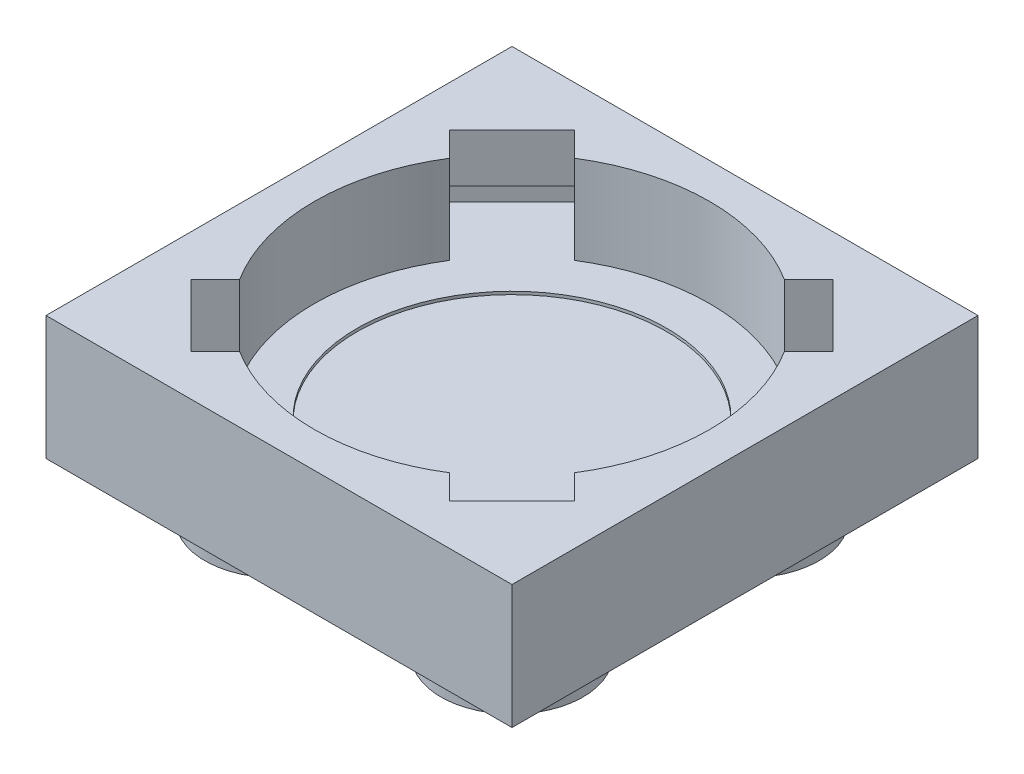
from build123d import *

# Parameters (mm, degrees)
SKETCH2_W            = 15.8
SKETCH2_H            = 15.8
BOSS_EXTRUDE2_DEPTH  = 4.2
SKETCH4_W            = 13.4
SKETCH4_H            = 13.4
CUT_EXTRUDE1_DEPTH   = 3
SKETCH6_R            = 2.41
BOSS_EXTRUDE4_DEPTH  = 1.8
LPATTERN1_COUNT      = 2
LPATTERN1_PITCH      = 8
LPATTERN1_COUNT_DIR2 = 2
LPATTERN1_PITCH_DIR2 = 8
SKETCH8_R            = 5.25
CUT_EXTRUDE2_DEPTH   = 0.1
BOSS_EXTRUDE9_DEPTH  = 3
CUT_EXTRUDE3_DEPTH   = 3
SKETCH20_W           = 3
SKETCH20_H           = 1.35
CUT_EXTRUDE4_DEPTH   = 1.25
CIRPATTERN3_COUNT    = 4


with BuildPart() as part:
    # Sketch2 → Boss-Extrude2 (new body)
    with BuildSketch(Plane(origin=(0, 0, 0), x_dir=(1, 0, 0), z_dir=(0, 1, 0))):
        with Locations((7.9, 7.9)):
            Rectangle(SKETCH2_W, SKETCH2_H)
    extrude(amount=-BOSS_EXTRUDE2_DEPTH)

    # Sketch4 → Cut-Extrude1 (cut)
    with BuildSketch(Plane(origin=(0, 0, 0), x_dir=(1, 0, 0), z_dir=(0, 1, 0))):
        with Locations((7.9, 7.9)):
            Rectangle(SKETCH4_W, SKETCH4_H)
    extrude(amount=-CUT_EXTRUDE1_DEPTH, mode=Mode.SUBTRACT)

    # Sketch6 → Boss-Extrude4 (add)
    with BuildSketch(Plane(origin=(0, -4.2, 0), x_dir=(-1, 0, 0), z_dir=(0, -1, 0))):
        with Locations((-11.9, 11.9)):
            Circle(SKETCH6_R)
    boss_extrude4 = extrude(amount=BOSS_EXTRUDE4_DEPTH)

    # LPattern1: Boss-Extrude4 2 × 2
    with Locations(*[(-j * LPATTERN1_PITCH_DIR2, 0, i * LPATTERN1_PITCH) for i in range(LPATTERN1_COUNT) for j in range(LPATTERN1_COUNT_DIR2) if (i, j) != (0, 0)]):
        add(boss_extrude4)

    # Sketch8 → Cut-Extrude2 (cut)
    with BuildSketch(Plane(origin=(0, -3, 0), x_dir=(1, 0, 0), z_dir=(0, 1, 0))):
        with Locations((7.9, 7.9)):
            Circle(SKETCH8_R)
    extrude(amount=-CUT_EXTRUDE2_DEPTH, mode=Mode.SUBTRACT)

    # Sketch11 → Boss-Extrude9 (add)
    with BuildSketch(Plane(origin=(0, -3, 0), x_dir=(1, 0, 0), z_dir=(0, 1, 0))):
        with BuildLine():
            Line((7.899999971, 14.6), (1.2, 14.6))
            Line((1.2, 14.6), (1.2, 7.9))
            ThreePointArc((1.2, 7.9), (3.162384556, 12.637615424), (7.899999971, 14.6))
        make_face()
        with BuildLine():
            Line((14.6, 14.6), (7.899999971, 14.6))
            ThreePointArc((7.899999971, 14.6), (12.637615424, 12.637615444), (14.6, 7.9))
            Line((14.6, 7.9), (14.6, 14.6))
        make_face()
        with BuildLine():
            ThreePointArc((7.900000011, 1.2), (3.16238457, 3.162384562), (1.2, 7.9))
            Line((1.2, 7.9), (1.2, 1.2))
            Line((1.2, 1.2), (7.900000011, 1.2))
        make_face()
        with BuildLine():
            Line((14.6, 1.2), (14.6, 7.9))
            ThreePointArc((14.6, 7.9), (12.637615438, 3.16238457), (7.900000011, 1.2))
            Line((7.900000011, 1.2), (14.6, 1.2))
        make_face()
    extrude(amount=BOSS_EXTRUDE9_DEPTH)

    # Sketch12 → Cut-Extrude3 (cut)
    with BuildSketch(Plane(origin=(0, 0, 0), x_dir=(1, 0, 0), z_dir=(0, 1, 0))):
        Polygon((3.162384566, 12.637615434), (2.455277785, 13.344722215), (1.394617613, 12.284062043), (2.101724394, 11.576955262), align=None)
        with BuildLine():
            ThreePointArc((2.221981276, 11.45669838), (2.658816927, 12.073727351), (3.162384566, 12.637615434))
            Line((3.162384566, 12.637615434), (2.101724394, 11.576955262))
            Line((2.101724394, 11.576955262), (2.221981276, 11.45669838))
        make_face()
        with BuildLine():
            Line((4.223044738, 13.698275606), (3.162384566, 12.637615434))
            ThreePointArc((3.162384566, 12.637615434), (3.726272649, 13.141183073), (4.34330162, 13.578018724))
            Line((4.34330162, 13.578018724), (4.223044738, 13.698275606))
        make_face()
        Polygon((3.515937957, 14.405382387), (2.455277785, 13.344722215), (3.162384566, 12.637615434), (4.223044738, 13.698275606), align=None)
        with BuildLine():
            ThreePointArc((4.34330162, 13.578018724), (3.726272649, 13.141183073), (3.162384566, 12.637615434))
            ThreePointArc((3.162384566, 12.637615434), (2.658816927, 12.073727351), (2.221981276, 11.45669838))
            Line((2.221981276, 11.45669838), (2.423581348, 11.255098309))
            Line((2.423581348, 11.255098309), (4.544901691, 13.376418652))
            Line((4.544901691, 13.376418652), (4.34330162, 13.578018724))
        make_face()
        with BuildLine():
            ThreePointArc((14.6, 7.9), (11.145005458, 13.761735202), (4.34330162, 13.578018724))
            Line((4.34330162, 13.578018724), (4.544901691, 13.376418652))
            Line((4.544901691, 13.376418652), (2.423581348, 11.255098309))
            Line((2.423581348, 11.255098309), (2.221981276, 11.45669838))
            ThreePointArc((2.221981276, 11.45669838), (6.049692654, 1.460561925), (14.6, 7.9))
        make_face()
    cut_extrude3 = extrude(amount=-CUT_EXTRUDE3_DEPTH, mode=Mode.SUBTRACT)

    # Sketch20 → Cut-Extrude4 (cut)
    with BuildSketch(Plane(origin=(-5.444722215, 0, -5.444722215), x_dir=(0.707106781, 0, -0.707106781), z_dir=(0.707106781, 0, 0.707106781))):
        with Locations((11.172287143, -2.325)):
            Rectangle(SKETCH20_W, SKETCH20_H)
    cut_extrude4 = extrude(amount=-CUT_EXTRUDE4_DEPTH, mode=Mode.SUBTRACT)

    # CirPattern3: Cut-Extrude3, Cut-Extrude4 ×4 about axis
    cirpattern3_axis = Axis((7.9, 0, -7.9), (0, 1, 0))
    for i in range(1, CIRPATTERN3_COUNT):
        add(cut_extrude3.rotate(cirpattern3_axis, i * 360 / CIRPATTERN3_COUNT), mode=Mode.SUBTRACT)
        add(cut_extrude4.rotate(cirpattern3_axis, i * 360 / CIRPATTERN3_COUNT), mode=Mode.SUBTRACT)


solid = part.part
